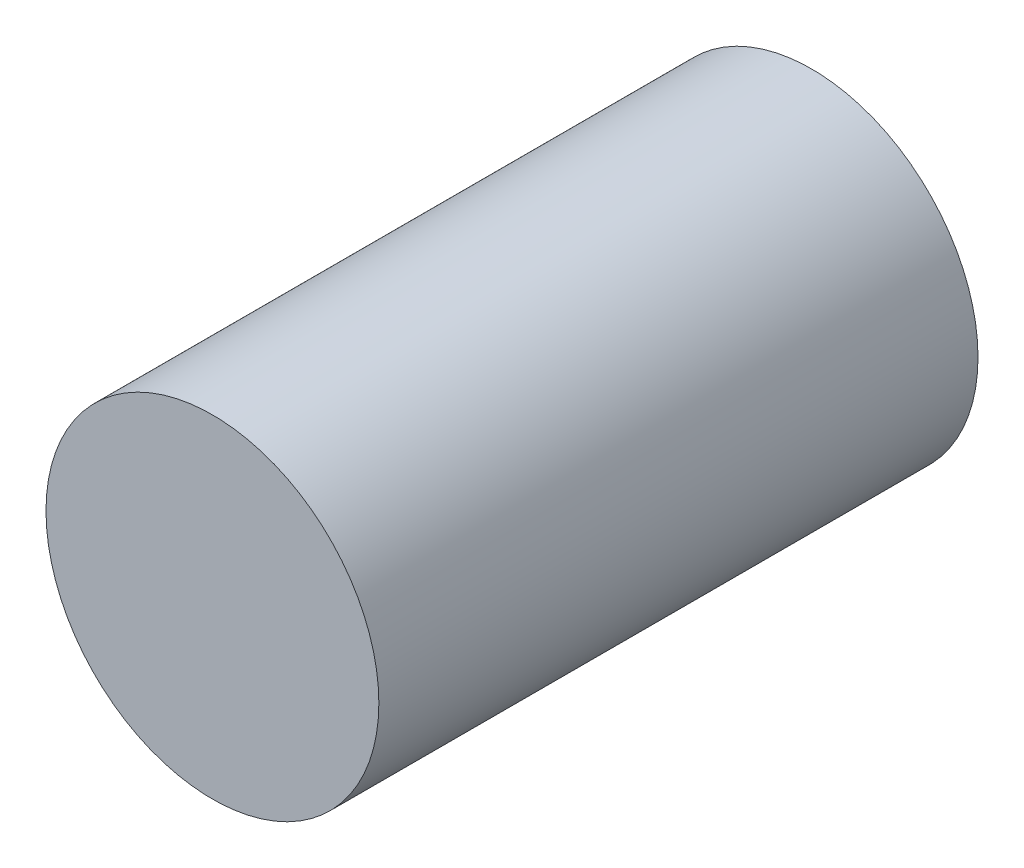
from build123d import *

# Parameters (mm, degrees)
SKETCH1_R           = 5
BOSS_EXTRUDE1_DEPTH = 9


with BuildPart() as part:
    # Sketch1 → Boss-Extrude1 (new body, symmetric)
    with BuildSketch(Plane.XY):
        Circle(SKETCH1_R)
    extrude(amount=BOSS_EXTRUDE1_DEPTH, both=True)


solid = part.part
